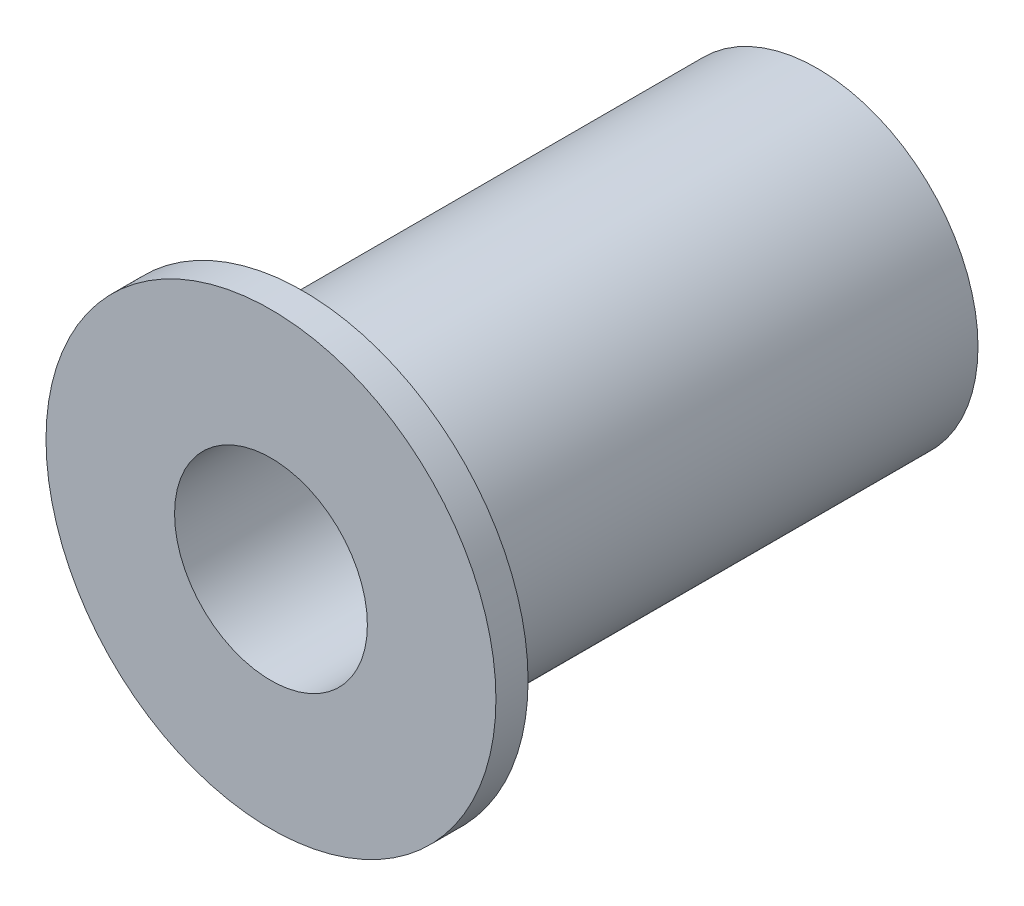
from build123d import *

# Parameters (mm, degrees)
SKETCH1_R           = 7.9375
SKETCH1_R_2         = 4.7625
BOSS_EXTRUDE1_DEPTH = 25.4
SKETCH2_R           = 11.1125
SKETCH2_R_2         = 4.7625
BOSS_EXTRUDE2_DEPTH = 1.5875


with BuildPart() as part:
    # Sketch1 → Boss-Extrude1 (new body)
    with BuildSketch(Plane.XY):
        Circle(SKETCH1_R)
        Circle(SKETCH1_R_2, mode=Mode.SUBTRACT)
    extrude(amount=BOSS_EXTRUDE1_DEPTH)

    # Sketch2 → Boss-Extrude2 (add)
    with BuildSketch(Plane.XY.offset(25.4)):
        Circle(SKETCH2_R)
        Circle(SKETCH2_R_2, mode=Mode.SUBTRACT)
    extrude(amount=BOSS_EXTRUDE2_DEPTH)


solid = part.part
